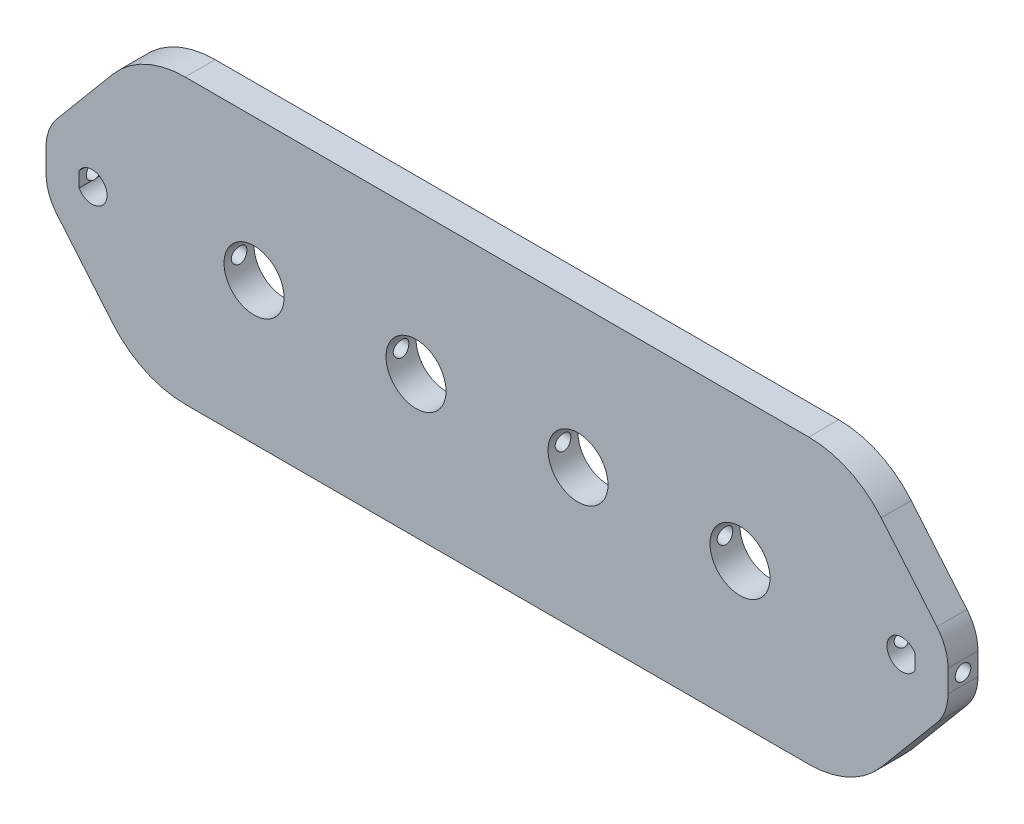
from build123d import *

# Parameters (mm, degrees)
SKETCH1_R             = 6.35
BOSS_EXTRUDE1_DEPTH   = 3.175
FILLET2_R             = 10
FILLET3_R             = 20
M4X0_7_TAPPED_HOLE1_D = 3.3


with BuildPart() as part:
    # Sketch1 → Boss-Extrude1 (new body, symmetric)
    with BuildSketch(Plane.XY):
        Polygon((75.336239509, 30), (-75.336239509, 30), (-95.474630657, 6), (-95.474630657, -6), (-75.336239509, -30), (75.336239509, -30), (95.474630657, -6), (95.474630657, 6), align=None)
        with BuildLine():
            Line((-88.474630657, -1.5875), (-88.474630657, 1.5875))
            ThreePointArc((-88.474630657, 1.5875), (-82.55, 0), (-88.474630657, -1.5875))
        make_face(mode=Mode.SUBTRACT)
        with Locations((-51.435, 0)):
            Circle(SKETCH1_R, mode=Mode.SUBTRACT)
        with Locations((-17.145, 0)):
            Circle(SKETCH1_R, mode=Mode.SUBTRACT)
        with Locations((17.145, 0)):
            Circle(SKETCH1_R, mode=Mode.SUBTRACT)
        with Locations((51.435, 0)):
            Circle(SKETCH1_R, mode=Mode.SUBTRACT)
        with BuildLine():
            ThreePointArc((88.474630657, -1.5875), (82.55, 0), (88.474630657, 1.5875))
            Line((88.474630657, 1.5875), (88.474630657, -1.5875))
        make_face(mode=Mode.SUBTRACT)
    extrude(amount=BOSS_EXTRUDE1_DEPTH, both=True)

    # Fillet2
    fillet2_edges = [part.edges().sort_by_distance(p)[0] for p in [
        (95.474630657, 6, 0),
        (95.474630657, -6, 0),
        (-95.474630657, -6, 0),
        (-95.474630657, 6, 0),
    ]]
    fillet(fillet2_edges, radius=FILLET2_R)

    # Fillet3
    fillet3_edges = [part.edges().sort_by_distance(p)[0] for p in [
        (75.336239509, -30, 0),
        (-75.336239509, -30, 0),
        (-75.336239509, 30, 0),
        (75.336239509, 30, 0),
    ]]
    fillet(fillet3_edges, radius=FILLET3_R)

    # M4x0.7 Tapped Hole1 (through all)
    with Locations(Plane.ZY.offset(95.474630657)):
        with Locations((0, 0)):
            Hole(M4X0_7_TAPPED_HOLE1_D / 2)


solid = part.part
